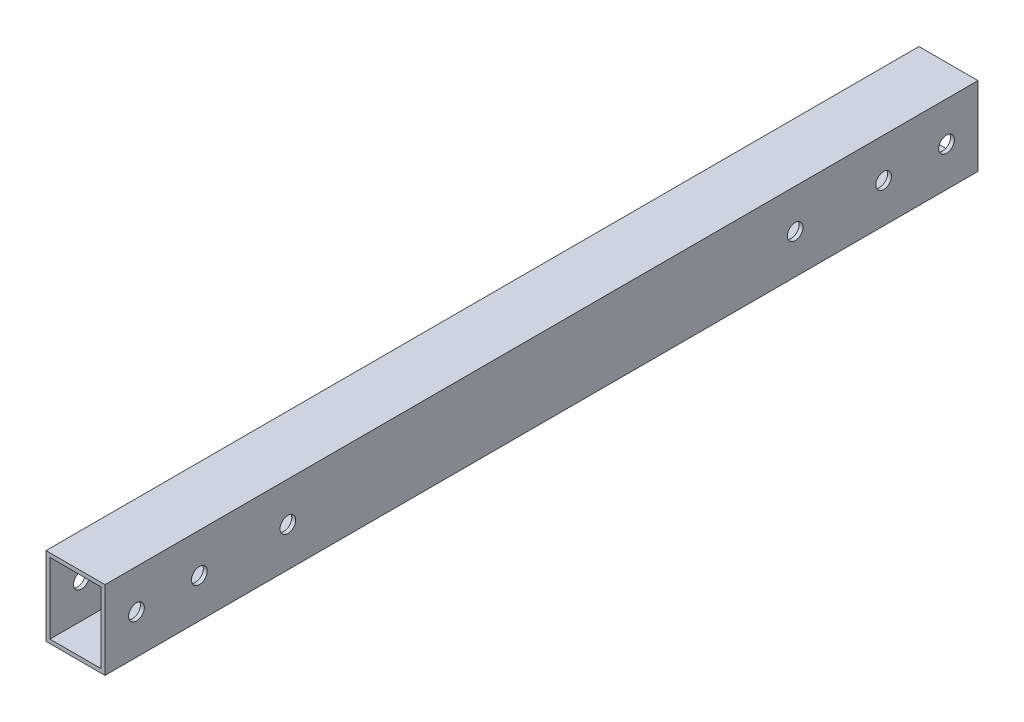
from build123d import *

# Parameters (mm, degrees)
SKETCH_1_W          = 30
SKETCH_1_H          = 40
SKETCH_1_W_2        = 26
SKETCH_1_H_2        = 36
EXTRUDE_1_DEPTH     = 444
SKETCH_2_R          = 4
CUT_EXTRUDE_1_DEPTH = 96


with BuildPart() as part:
    # 草图1 → 凸台-拉伸1 (new body)
    with BuildSketch(Plane.XY):
        with Locations((-3.063208411, -0.691053078)):
            Rectangle(SKETCH_1_W, SKETCH_1_H)
        with Locations((-3.063208411, -0.691053078)):
            Rectangle(SKETCH_1_W_2, SKETCH_1_H_2, mode=Mode.SUBTRACT)
    extrude(amount=EXTRUDE_1_DEPTH)

    # 草图2 → 切除-拉伸1 (cut)
    with BuildSketch(Plane.ZY.offset(18.063208411)):
        with Locations((396, -0.691053078)):
            Circle(SKETCH_2_R)
        with Locations((428, -0.691053078)):
            Circle(SKETCH_2_R)
        with Locations((16, -0.691053078)):
            Circle(SKETCH_2_R)
        with Locations((48, -0.691053078)):
            Circle(SKETCH_2_R)
        with Locations((93, -0.691053078)):
            Circle(SKETCH_2_R)
        with Locations((351, -0.691053078)):
            Circle(SKETCH_2_R)
    extrude(amount=-CUT_EXTRUDE_1_DEPTH, mode=Mode.SUBTRACT)


solid = part.part
